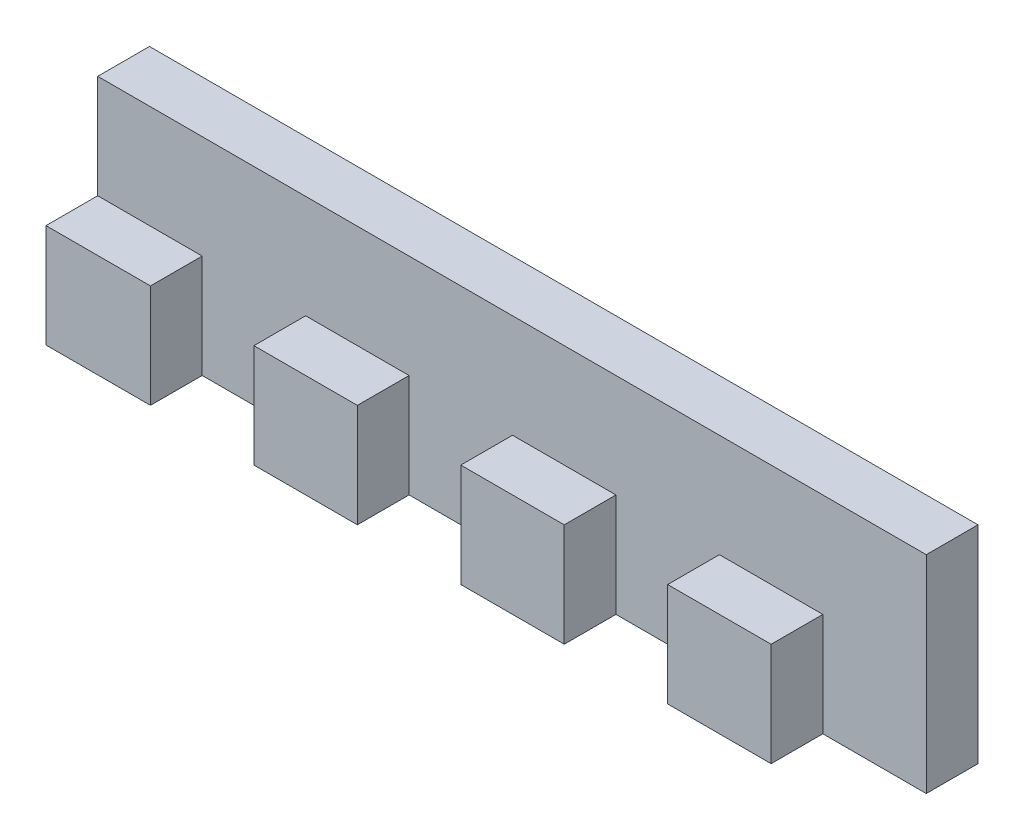
from build123d import *

# Parameters (mm, degrees)
EXTRUDE_1_DEPTH     = 20
SKETCH_2_W          = 5
SKETCH_2_H          = 10
CUT_EXTRUDE_1_DEPTH = 81.099407002


with BuildPart() as part:
    # Эскиз1 → Бобышка-Вытянуть1 (new body)
    with BuildSketch(Plane(origin=(0, 0, 0), x_dir=(1, 0, 0), z_dir=(0, 1, 0))):
        Polygon((0, 0), (10.099407002, 0), (10.099407002, 5), (20.099407002, 5), (20.099407002, 0), (30.099407002, 0), (30.099407002, 5), (40.099407002, 5), (40.099407002, 0), (50.099407002, 0), (50.099407002, 5), (60.099407002, 5), (60.099407002, 0), (70.099407002, 0), (70.099407002, 5), (80.099407002, 5), (80.099407002, 10), (0, 10), align=None)
    extrude(amount=EXTRUDE_1_DEPTH)

    # Эскиз2 → Вырез-Вытянуть1 (cut, through all)
    with BuildSketch(Plane.ZY):
        with Locations((-2.5, 15)):
            Rectangle(SKETCH_2_W, SKETCH_2_H)
    extrude(amount=-CUT_EXTRUDE_1_DEPTH, mode=Mode.SUBTRACT)


solid = part.part
